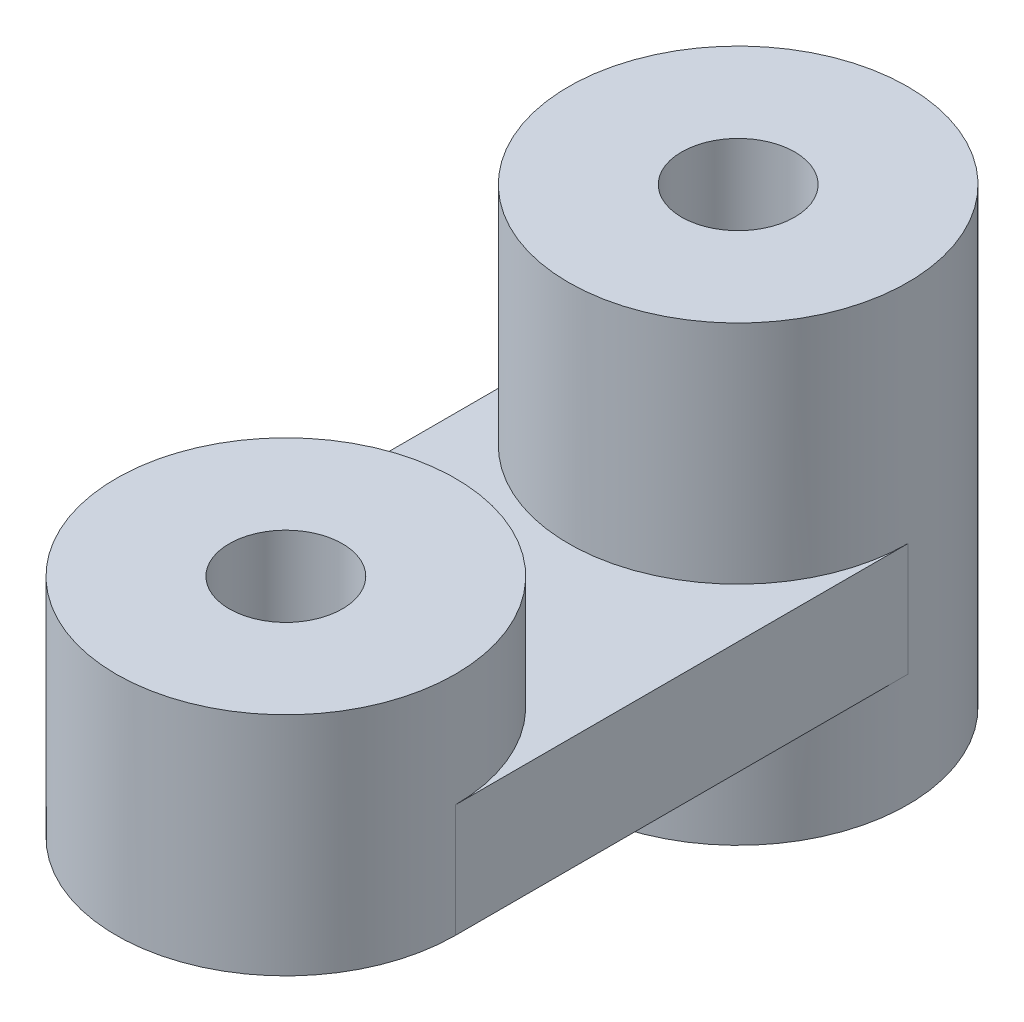
from build123d import *

# Parameters (mm, degrees)
CROQUIS3_R              = 2.5
SALIENTE_EXTRUIR1_DEPTH = 5
CROQUIS4_R              = 7.5
CROQUIS4_R_2            = 2.5
SALIENTE_EXTRUIR2_DEPTH = 5
CROQUIS5_R              = 7.5
CROQUIS5_R_2            = 2.5
SALIENTE_EXTRUIR3_DEPTH = 10
CROQUIS7_R              = 7.5
CROQUIS7_R_2            = 2.5
SALIENTE_EXTRUIR4_DEPTH = 5


with BuildPart() as part:
    # Croquis3 → Saliente-Extruir1 (new body)
    with BuildSketch(Plane(origin=(0, 0, 0), x_dir=(1, 0, 0), z_dir=(0, 1, 0))):
        with BuildLine():
            Line((-7.5, -7.5), (-7.5, 12.5))
            ThreePointArc((-7.5, 12.5), (0, 20), (7.5, 12.5))
            Line((7.5, 12.5), (7.5, -7.5))
            ThreePointArc((7.5, -7.5), (0, -15), (-7.5, -7.5))
        make_face()
        with Locations((0, 12.5)):
            Circle(CROQUIS3_R, mode=Mode.SUBTRACT)
        with Locations((0, -7.5)):
            Circle(CROQUIS3_R, mode=Mode.SUBTRACT)
    extrude(amount=SALIENTE_EXTRUIR1_DEPTH)

    # Croquis4 → Saliente-Extruir2 (add)
    with BuildSketch(Plane(origin=(0, 5, 0), x_dir=(1, 0, 0), z_dir=(0, 1, 0))):
        with Locations((0, -7.5)):
            Circle(CROQUIS4_R)
        with Locations((0, -7.5)):
            Circle(CROQUIS4_R_2, mode=Mode.SUBTRACT)
    extrude(amount=SALIENTE_EXTRUIR2_DEPTH)

    # Croquis5 → Saliente-Extruir3 (add)
    with BuildSketch(Plane(origin=(0, 5, 0), x_dir=(1, 0, 0), z_dir=(0, 1, 0))):
        with Locations((0, 12.5)):
            Circle(CROQUIS5_R)
        with Locations((0, 12.5)):
            Circle(CROQUIS5_R_2, mode=Mode.SUBTRACT)
    extrude(amount=SALIENTE_EXTRUIR3_DEPTH)

    # Croquis7 → Saliente-Extruir4 (add)
    with BuildSketch(Plane.XZ):
        with Locations((0, -12.5)):
            Circle(CROQUIS7_R)
        with Locations((0, -12.5)):
            Circle(CROQUIS7_R_2, mode=Mode.SUBTRACT)
    extrude(amount=SALIENTE_EXTRUIR4_DEPTH)


solid = part.part
